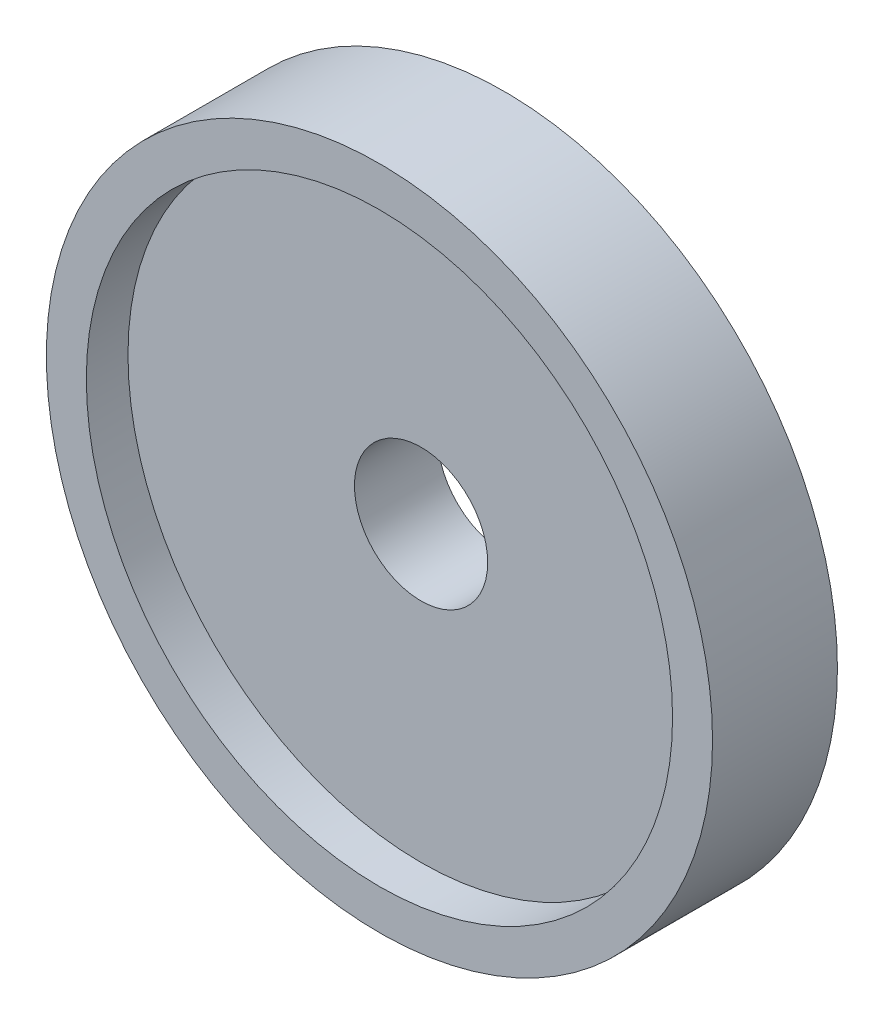
from build123d import *

# Parameters (mm, degrees)
SKETCH1_R           = 2
BOSS_EXTRUDE2_DEPTH = 0.75
SKETCH3_R           = 1.76
CUT_EXTRUDE1_DEPTH  = 0.25
SKETCH4_R           = 0.4
CUT_EXTRUDE2_DEPTH  = 1.5


with BuildPart() as part:
    # Sketch1 → Boss-Extrude2 (new body)
    with BuildSketch(Plane.XY):
        Circle(SKETCH1_R)
    extrude(amount=BOSS_EXTRUDE2_DEPTH)

    # Sketch3 → Cut-Extrude1 (cut)
    with BuildSketch(Plane.XY.offset(0.75)):
        Circle(SKETCH3_R)
    extrude(amount=-CUT_EXTRUDE1_DEPTH, mode=Mode.SUBTRACT)

    # Sketch4 → Cut-Extrude2 (cut, through all)
    with BuildSketch(Plane.XY.offset(0.5)):
        Circle(SKETCH4_R)
    extrude(amount=-CUT_EXTRUDE2_DEPTH, mode=Mode.SUBTRACT)


solid = part.part
